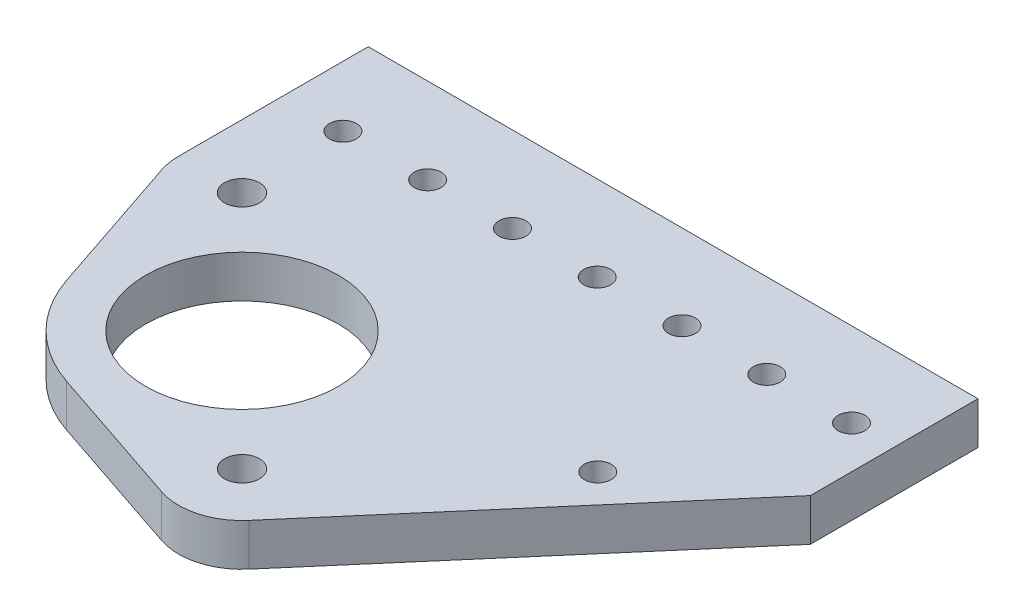
from build123d import *

# Parameters (mm, degrees)
SKETCH1_R           = 2.0193
SKETCH1_R_2         = 14.478
SKETCH1_R_3         = 2.6289
BOSS_EXTRUDE1_DEPTH = 6.35


with BuildPart() as part:
    # Sketch1 → Boss-Extrude1 (new body)
    with BuildSketch(Plane(origin=(0, 0, 0), x_dir=(1, 0, 0), z_dir=(0, 1, 0))):
        with BuildLine():
            Line((-313.888905321, 171.087609001), (-222.249489346, 171.087609001))
            Line((-222.249489346, 171.087609001), (-222.249489346, 145.888937334))
            Line((-222.249489346, 145.888937334), (-261.213202804, 100.464511352))
            ThreePointArc((-261.213202804, 100.464511352), (-265.91335193, 97.482933567), (-271.477290762, 97.637181964))
            Line((-271.477290762, 97.637181964), (-293.038636115, 104.883600221))
            ThreePointArc((-293.038636115, 104.883600221), (-301.131013118, 109.898805053), (-306.14621795, 117.991182056))
            Line((-306.14621795, 117.991182056), (-313.392636207, 139.552527409))
            ThreePointArc((-313.392636207, 139.552527409), (-313.764019328, 141.049575419), (-313.888905321, 142.586937334))
            Line((-313.888905321, 142.586937334), (-313.888905321, 171.087609001))
        make_face()
        with Locations((-228.599489346, 158.427874667)):
            Circle(SKETCH1_R, mode=Mode.SUBTRACT)
        with Locations((-241.299425514, 158.387609001)):
            Circle(SKETCH1_R, mode=Mode.SUBTRACT)
        with Locations((-253.999361682, 158.347343334)):
            Circle(SKETCH1_R, mode=Mode.SUBTRACT)
        with Locations((-266.69929785, 158.307077667)):
            Circle(SKETCH1_R, mode=Mode.SUBTRACT)
        with Locations((-279.399234018, 158.266812001)):
            Circle(SKETCH1_R, mode=Mode.SUBTRACT)
        with Locations((-292.099170186, 158.226546334)):
            Circle(SKETCH1_R, mode=Mode.SUBTRACT)
        with Locations((-304.799106355, 158.186280667)):
            Circle(SKETCH1_R, mode=Mode.SUBTRACT)
        with Locations((-286.403393079, 124.626425091)):
            Circle(SKETCH1_R_2, mode=Mode.SUBTRACT)
        with Locations((-268.442880837, 106.665912849)):
            Circle(SKETCH1_R_3, mode=Mode.SUBTRACT)
        with Locations((-304.363905321, 142.586937334)):
            Circle(SKETCH1_R_3, mode=Mode.SUBTRACT)
        with Locations((-241.299425514, 132.987609001)):
            Circle(SKETCH1_R, mode=Mode.SUBTRACT)
    extrude(amount=BOSS_EXTRUDE1_DEPTH)


solid = part.part
